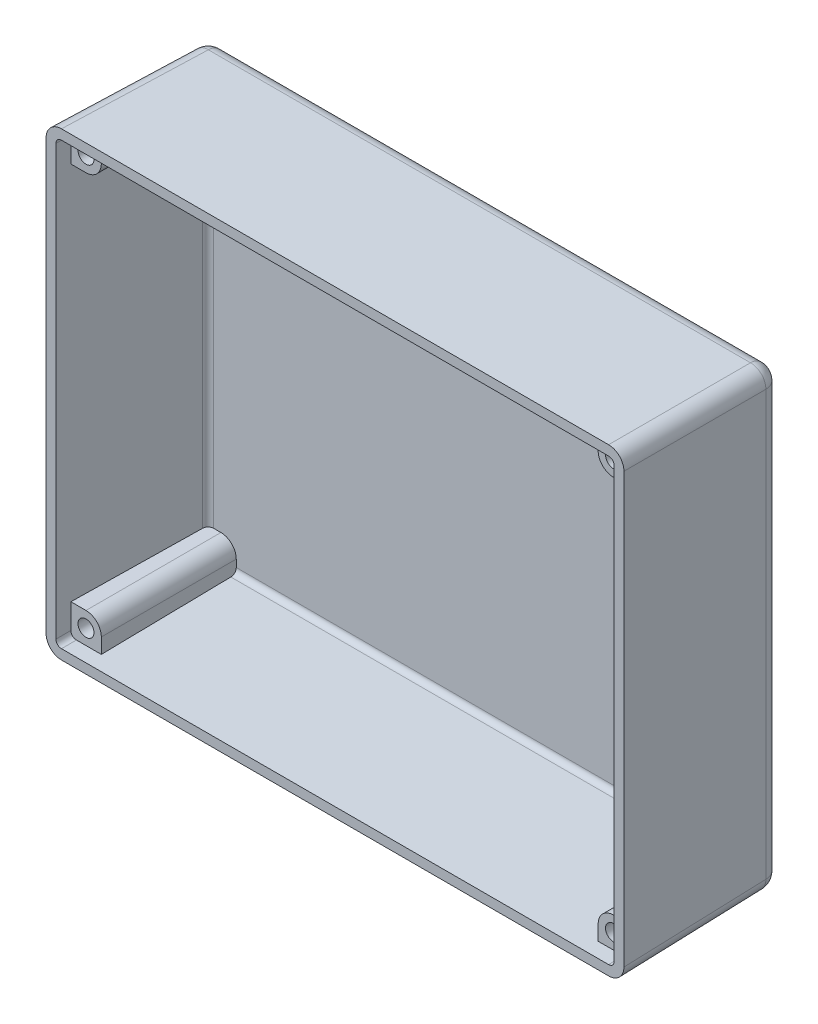
from build123d import *

# Parameters (mm, degrees)
SKETCH1_W                       = 119.634
SKETCH1_H                       = 95.25
BOSS_EXTRUDE1_DEPTH             = 33.02
BOSS_EXTRUDE1_DRAFT             = -1
FILLET1_R                       = 3.175
SHELL1_T                        = -2.032
BOSS_EXTRUDE2_DEPTH             = 27.94
TAP_DRILL_FOR_M4X0_7_TAP1_D     = 3.3
TAP_DRILL_FOR_M4X0_7_TAP1_DEPTH = 25.4
TAP_DRILL_FOR_M4X0_7_TAP1_TIP   = 0.991420021


with BuildPart() as part:
    # Sketch1 → Boss-Extrude1 (with draft: the straight prism first)
    with BuildSketch(Plane.XY):
        with Locations((59.817, 47.625)):
            Rectangle(SKETCH1_W, SKETCH1_H)
    extrude(amount=-BOSS_EXTRUDE1_DEPTH)
    # Boss-Extrude1: the draft: its side faces are tilted about the plane it starts from
    boss_extrude1_sides = [part.faces().sort_by_distance(p)[0] for p in [
        (59.817, 0, -16.51),
        (119.634, 47.625, -16.51),
        (59.817, 95.25, -16.51),
        (0, 47.625, -16.51),
    ]]
    draft(boss_extrude1_sides, Plane.XY, BOSS_EXTRUDE1_DRAFT)

    # Fillet1
    fillet1_edges = [part.edges().sort_by_distance(p)[0] for p in [
        (119.057633756, 47.625, -33.02),
        (59.817, 94.673633756, -33.02),
        (0.576366244, 47.625, -33.02),
        (59.817, 0.576366244, -33.02),
        (0.288183122, 94.961816878, -16.51),
        (119.345816878, 94.961816878, -16.51),
        (119.345816878, 0.288183122, -16.51),
        (0.288183122, 0.288183122, -16.51),
    ]]
    fillet(fillet1_edges, radius=FILLET1_R)

    # Shell1
    shell1_openings = [part.faces().sort_by_distance(p)[0] for p in [
        (59.817, 47.625, 0),
    ]]
    offset(amount=SHELL1_T, openings=shell1_openings, kind=Kind.INTERSECTION)

    # Sketch2 → Boss-Extrude2 (add)
    with BuildSketch(Plane.XY.offset(-30.988)):
        with BuildLine():
            Line((2.032309531, 86.867690469), (5.207309531, 86.867690469))
            ThreePointArc((5.207309531, 86.867690469), (7.452373561, 87.797626439), (8.382309531, 90.042690469))
            Line((8.382309531, 90.042690469), (8.382309531, 93.217690469))
            Line((8.382309531, 93.217690469), (3.175135446, 93.217690469))
            ThreePointArc((3.175135446, 93.217690469), (2.367035492, 92.882964508), (2.032309531, 92.074864554))
            Line((2.032309531, 92.074864554), (2.032309531, 86.867690469))
        make_face()
        with BuildLine():
            Line((111.251690469, 93.217690469), (111.251690469, 90.042690469))
            ThreePointArc((111.251690469, 90.042690469), (112.181626439, 87.797626439), (114.426690469, 86.867690469))
            Line((114.426690469, 86.867690469), (117.601690469, 86.867690469))
            Line((117.601690469, 86.867690469), (117.601690469, 92.074864554))
            ThreePointArc((117.601690469, 92.074864554), (117.266964508, 92.882964508), (116.458864554, 93.217690469))
            Line((116.458864554, 93.217690469), (111.251690469, 93.217690469))
        make_face()
        with BuildLine():
            Line((116.458864554, 2.032309531), (111.251690469, 2.032309531))
            Line((111.251690469, 2.032309531), (111.251690469, 5.207309531))
            ThreePointArc((111.251690469, 5.207309531), (112.181626439, 7.452373561), (114.426690469, 8.382309531))
            Line((114.426690469, 8.382309531), (117.601690469, 8.382309531))
            Line((117.601690469, 8.382309531), (117.601690469, 3.175135446))
            ThreePointArc((117.601690469, 3.175135446), (117.266964508, 2.367035492), (116.458864554, 2.032309531))
        make_face()
        with BuildLine():
            Line((2.032309531, 3.175135446), (2.032309531, 8.382309531))
            Line((2.032309531, 8.382309531), (5.207309531, 8.382309531))
            ThreePointArc((5.207309531, 8.382309531), (7.452373561, 7.452373561), (8.382309531, 5.207309531))
            Line((8.382309531, 5.207309531), (8.382309531, 2.032309531))
            Line((8.382309531, 2.032309531), (3.175135446, 2.032309531))
            ThreePointArc((3.175135446, 2.032309531), (2.367035492, 2.367035492), (2.032309531, 3.175135446))
        make_face()
    extrude(amount=BOSS_EXTRUDE2_DEPTH)

    # Tap Drill for M4x0.7 Tap1
    with Locations(Plane.XY.offset(-3.048)):
        with Locations((5.207309531, 90.042690469), (114.426690469, 90.042690469), (114.426690469, 5.207309531), (5.207309531, 5.207309531)):
            Hole(TAP_DRILL_FOR_M4X0_7_TAP1_D / 2, depth=TAP_DRILL_FOR_M4X0_7_TAP1_DEPTH)
            with Locations((0, 0, -(TAP_DRILL_FOR_M4X0_7_TAP1_DEPTH + TAP_DRILL_FOR_M4X0_7_TAP1_TIP / 2))):  # 118° drill point
                Cone(0, TAP_DRILL_FOR_M4X0_7_TAP1_D / 2, TAP_DRILL_FOR_M4X0_7_TAP1_TIP, mode=Mode.SUBTRACT)


solid = part.part
